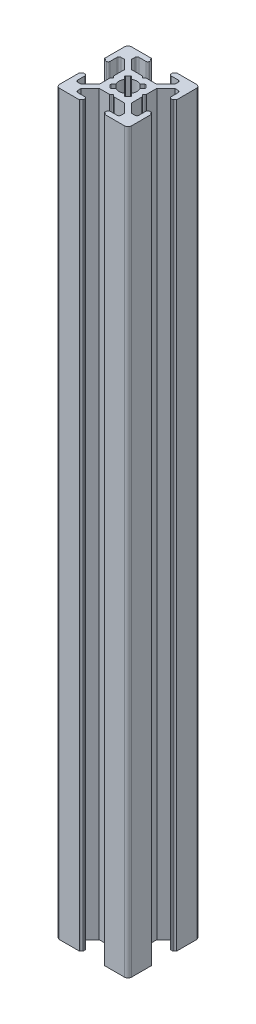
from build123d import *

# Parameters (mm, degrees)
BOSS_EXTRUDE1_DEPTH = 205
FILLET1_R           = 1
CUT_EXTRUDE1_DEPTH  = 206
FILLET2_R           = 0.5
FILLET3_R           = 0.25


with BuildPart() as part:
    # Sketch3 → Boss-Extrude1 (new body)
    with BuildSketch(Plane(origin=(0, 0, 0), x_dir=(1, 0, 0), z_dir=(0, 1, 0))):
        with BuildLine():
            Line((7, 18.5), (7, 19.5))
            ThreePointArc((7, 19.5), (6.646446609, 19.646446609), (6.5, 20))
            Line((6.5, 20), (0, 20))
            Line((0, 20), (0, 13.5))
            ThreePointArc((0, 13.5), (0.353553391, 13.353553391), (0.5, 13))
            Line((0.5, 13), (1.5, 13))
            Line((1.5, 13), (1.5, 16))
            Line((1.5, 16), (3, 16))
            Line((3, 16), (5.5, 13.5))
            Line((5.5, 13.5), (5.5, 10.5))
            Line((5.5, 10.5), (6, 10))
            Line((6, 10), (5.5, 9.5))
            Line((5.5, 9.5), (5.5, 6.5))
            Line((5.5, 6.5), (3, 4))
            Line((3, 4), (1.5, 4))
            Line((1.5, 4), (1.5, 7))
            Line((1.5, 7), (0.5, 7))
            ThreePointArc((0.5, 7), (0.353553391, 6.646446609), (0, 6.5))
            Line((0, 6.5), (0, 0))
            Line((0, 0), (6.5, 0))
            ThreePointArc((6.5, 0), (6.646446609, 0.353553391), (7, 0.5))
            Line((7, 0.5), (7, 1.5))
            Line((7, 1.5), (4, 1.5))
            Line((4, 1.5), (4, 3))
            Line((4, 3), (6.5, 5.5))
            Line((6.5, 5.5), (9.5, 5.5))
            Line((9.5, 5.5), (10, 6))
            Line((10, 6), (10.5, 5.5))
            Line((10.5, 5.5), (13.5, 5.5))
            Line((13.5, 5.5), (16, 3))
            Line((16, 3), (16, 1.5))
            Line((16, 1.5), (13, 1.5))
            Line((13, 1.5), (13, 0.5))
            ThreePointArc((13, 0.5), (13.353553391, 0.353553391), (13.5, 0))
            Line((13.5, 0), (20, 0))
            Line((20, 0), (20, 6.5))
            ThreePointArc((20, 6.5), (19.646446609, 6.646446609), (19.5, 7))
            Line((19.5, 7), (18.5, 7))
            Line((18.5, 7), (18.5, 4))
            Line((18.5, 4), (17, 4))
            Line((17, 4), (14.5, 6.5))
            Line((14.5, 6.5), (14.5, 9.5))
            Line((14.5, 9.5), (14, 10))
            Line((14, 10), (14.5, 10.5))
            Line((14.5, 10.5), (14.5, 13.5))
            Line((14.5, 13.5), (17, 16))
            Line((17, 16), (18.5, 16))
            Line((18.5, 16), (18.5, 13))
            Line((18.5, 13), (19.5, 13))
            ThreePointArc((19.5, 13), (19.646446609, 13.353553391), (20, 13.5))
            Line((20, 13.5), (20, 20))
            Line((20, 20), (13.5, 20))
            ThreePointArc((13.5, 20), (13.353553391, 19.646446609), (13, 19.5))
            Line((13, 19.5), (13, 18.5))
            Line((13, 18.5), (16, 18.5))
            Line((16, 18.5), (16, 17))
            Line((16, 17), (13.5, 14.5))
            Line((13.5, 14.5), (10.5, 14.5))
            Line((10.5, 14.5), (10, 14))
            Line((10, 14), (9.5, 14.5))
            Line((9.5, 14.5), (6.5, 14.5))
            Line((6.5, 14.5), (4, 17))
            Line((4, 17), (4, 18.5))
            Line((4, 18.5), (7, 18.5))
        make_face()
    extrude(amount=BOSS_EXTRUDE1_DEPTH)

    # Fillet1
    fillet1_edges = [part.edges().sort_by_distance(p)[0] for p in [
        (20, 102.5, 0),
        (0, 102.5, 0),
        (0, 102.5, -20),
        (20, 102.5, -20),
    ]]
    fillet(fillet1_edges, radius=FILLET1_R)

    # Sketch4 → Cut-Extrude1 (cut, through all)
    with BuildSketch(Plane(origin=(0, 205, 0), x_dir=(1, 0, 0), z_dir=(0, 1, 0))):
        with BuildLine():
            Line((10, 11), (11.195582496, 12.195582496))
            ThreePointArc((11.195582496, 12.195582496), (10, 12.5), (8.804417504, 12.195582496))
            Line((8.804417504, 12.195582496), (10, 11))
        make_face()
        with BuildLine():
            ThreePointArc((12.195582496, 11.195582496), (11.767766953, 11.767766953), (11.195582496, 12.195582496))
            Line((11.195582496, 12.195582496), (10, 11))
            Line((10, 11), (11, 10))
            Line((11, 10), (12.195582496, 11.195582496))
        make_face()
        with BuildLine():
            Line((9, 10), (10, 11))
            Line((10, 11), (8.804417504, 12.195582496))
            ThreePointArc((8.804417504, 12.195582496), (8.232233047, 11.767766953), (7.804417504, 11.195582496))
            Line((7.804417504, 11.195582496), (9, 10))
        make_face()
        Polygon((11, 10), (10, 11), (9, 10), (10, 9), align=None)
        with BuildLine():
            Line((7.804417504, 8.804417504), (9, 10))
            Line((9, 10), (7.804417504, 11.195582496))
            ThreePointArc((7.804417504, 11.195582496), (7.5, 10), (7.804417504, 8.804417504))
        make_face()
        with BuildLine():
            Line((10, 9), (9, 10))
            Line((9, 10), (7.804417504, 8.804417504))
            ThreePointArc((7.804417504, 8.804417504), (8.232233047, 8.232233047), (8.804417504, 7.804417504))
            Line((8.804417504, 7.804417504), (10, 9))
        make_face()
        with BuildLine():
            Line((11.195582496, 7.804417504), (10, 9))
            Line((10, 9), (8.804417504, 7.804417504))
            ThreePointArc((8.804417504, 7.804417504), (10, 7.5), (11.195582496, 7.804417504))
        make_face()
        with BuildLine():
            Line((12.195582496, 8.804417504), (11, 10))
            Line((11, 10), (10, 9))
            Line((10, 9), (11.195582496, 7.804417504))
            ThreePointArc((11.195582496, 7.804417504), (11.767766953, 8.232233047), (12.195582496, 8.804417504))
        make_face()
        with BuildLine():
            ThreePointArc((12.5, 10), (12.422700584, 10.616864556), (12.195582496, 11.195582496))
            Line((12.195582496, 11.195582496), (11, 10))
            Line((11, 10), (12.195582496, 8.804417504))
            ThreePointArc((12.195582496, 8.804417504), (12.422700584, 9.383135444), (12.5, 10))
        make_face()
        with BuildLine():
            ThreePointArc((8.804417504, 7.804417504), (8.232233047, 8.232233047), (7.804417504, 8.804417504))
            Line((7.804417504, 8.804417504), (7, 8))
            Line((7, 8), (8, 7))
            Line((8, 7), (8.804417504, 7.804417504))
        make_face()
        with BuildLine():
            Line((13, 8), (12.195582496, 8.804417504))
            ThreePointArc((12.195582496, 8.804417504), (11.767766953, 8.232233047), (11.195582496, 7.804417504))
            Line((11.195582496, 7.804417504), (12, 7))
            Line((12, 7), (13, 8))
        make_face()
        with BuildLine():
            Line((13, 12), (12, 13))
            Line((12, 13), (11.195582496, 12.195582496))
            ThreePointArc((11.195582496, 12.195582496), (11.767766953, 11.767766953), (12.195582496, 11.195582496))
            Line((12.195582496, 11.195582496), (13, 12))
        make_face()
        with BuildLine():
            ThreePointArc((7.804417504, 11.195582496), (8.232233047, 11.767766953), (8.804417504, 12.195582496))
            Line((8.804417504, 12.195582496), (8, 13))
            Line((8, 13), (7, 12))
            Line((7, 12), (7.804417504, 11.195582496))
        make_face()
    extrude(amount=-CUT_EXTRUDE1_DEPTH, mode=Mode.SUBTRACT)

    # Fillet2
    fillet2_edges = [part.edges().sort_by_distance(p)[0] for p in [
        (18.5, 102.5, -13),
        (18.5, 102.5, -16),
        (14.5, 102.5, -10.5),
        (14.5, 102.5, -9.5),
        (18.5, 102.5, -4),
        (18.5, 102.5, -7),
        (13, 102.5, -1.5),
        (16, 102.5, -1.5),
        (10.5, 102.5, -5.5),
        (9.5, 102.5, -5.5),
        (4, 102.5, -1.5),
        (7, 102.5, -1.5),
        (1.5, 102.5, -7),
        (1.5, 102.5, -4),
        (5.5, 102.5, -9.5),
        (5.5, 102.5, -10.5),
        (1.5, 102.5, -16),
        (1.5, 102.5, -13),
        (7, 102.5, -18.5),
        (4, 102.5, -18.5),
        (9.5, 102.5, -14.5),
        (10.5, 102.5, -14.5),
        (16, 102.5, -18.5),
        (13, 102.5, -18.5),
    ]]
    fillet(fillet2_edges, radius=FILLET2_R)

    # Fillet3
    fillet3_edges = [part.edges().sort_by_distance(p)[0] for p in [
        (7, 102.5, -12),
        (8, 102.5, -13),
        (12, 102.5, -13),
        (13, 102.5, -12),
        (13, 102.5, -8),
        (12, 102.5, -7),
        (8, 102.5, -7),
        (7, 102.5, -8),
    ]]
    fillet(fillet3_edges, radius=FILLET3_R)


solid = part.part
